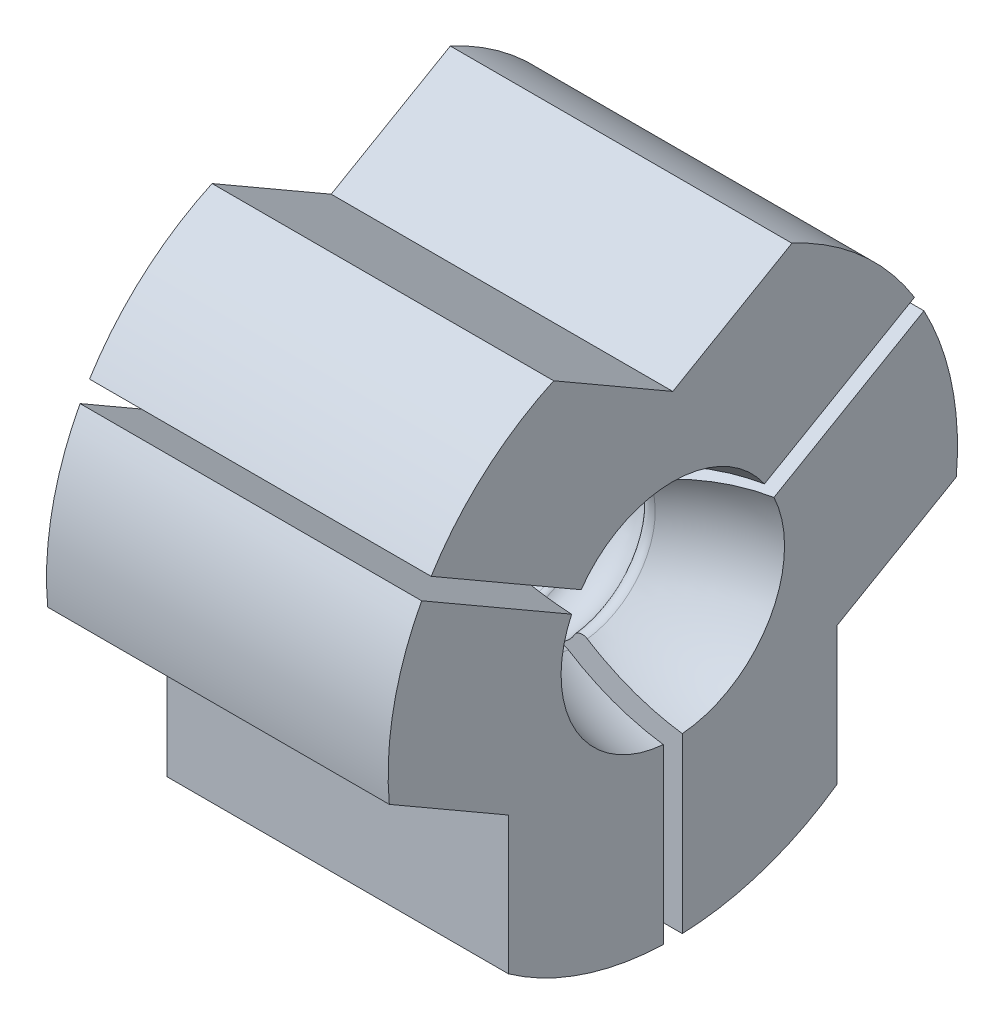
from build123d import *

# Parameters (mm, degrees)
BOSS_EXTRUDE1_START = 2
BOSS_EXTRUDE1_DEPTH = 18
CIRPATTERN1_COUNT   = 3


with BuildPart() as part:
    # Sketch1 → Revolve1 (revolve)
    with BuildSketch(Plane.XY):
        with BuildLine():
            Line((0, 0), (0, -7.5))
            Line((0, -7.5), (3, -7.5))
            Line((3, -7.5), (3, -7.285575219))
            ThreePointArc((3, -7.285575219), (3.328989928, -6.815728909), (3.883022222, -6.964181415))
            ThreePointArc((3.883022222, -6.964181415), (5.167303657, -7.493893224), (6.335602465, -6.742194281))
            ThreePointArc((6.335602465, -6.742194281), (8.556960549, -4.689592316), (11.555384824, -4.293286331))
            ThreePointArc((11.555384824, -4.293286331), (11.718196726, -4.352727542), (11.850933335, -4.464181415))
            ThreePointArc((11.850933335, -4.464181415), (13.130733614, -4.994292047), (14.299038106, -4.25))
            ThreePointArc((14.299038106, -4.25), (14.611545364, -4.014738794), (14.99780611, -4.076474181))
            ThreePointArc((14.99780611, -4.076474181), (23.142626347, -5.914921595), (30.643716256, -2.247274425))
            ThreePointArc((30.643716256, -2.247274425), (30.932815796, -2.102610488), (31.25, -2.165063509))
            ThreePointArc((31.25, -2.165063509), (33.75, -2.165063509), (35, 0))
            Line((35, 0), (0, 0))
        make_face()
    revolve(axis=Axis((0, 0, 0), (-1, 0, 0)))


with BuildPart() as body_2:
    # Sketch3 → Boss-Extrude1 (new body)
    with BuildSketch(Plane(origin=(0, 0, 0), x_dir=(0, 0, -1), z_dir=(1, 0, 0)).offset(BOSS_EXTRUDE1_START)):
        with BuildLine():
            Line((12.733162173, 7.928844877), (0, 0.577350269))
            Line((0, 0.577350269), (-12.733162173, 7.928844877))
            ThreePointArc((-12.733162173, 7.928844877), (-9.922171464, 11.249467251), (-6.276474699, 13.623724357))
            Line((-6.276474699, 13.623724357), (0, 10))
            Line((0, 10), (6.276474699, 13.623724357))
            ThreePointArc((6.276474699, 13.623724357), (9.922171464, 11.249467251), (12.733162173, 7.928844877))
        make_face()
    extrude(amount=BOSS_EXTRUDE1_DEPTH)

    # Combine1: cut part
    add(part.part, mode=Mode.SUBTRACT)


with BuildPart() as cirpattern1_1:
    # CirPattern1: pattern copy
    add(body_2.part.rotate(Axis((0, 0, 0), (1, 0, 0)), 1 * 360 / CIRPATTERN1_COUNT))


with BuildPart() as cirpattern1_2:
    # CirPattern1: pattern copy
    add(body_2.part.rotate(Axis((0, 0, 0), (1, 0, 0)), 2 * 360 / CIRPATTERN1_COUNT))


solid = Compound([body_2.part, cirpattern1_1.part, cirpattern1_2.part])
